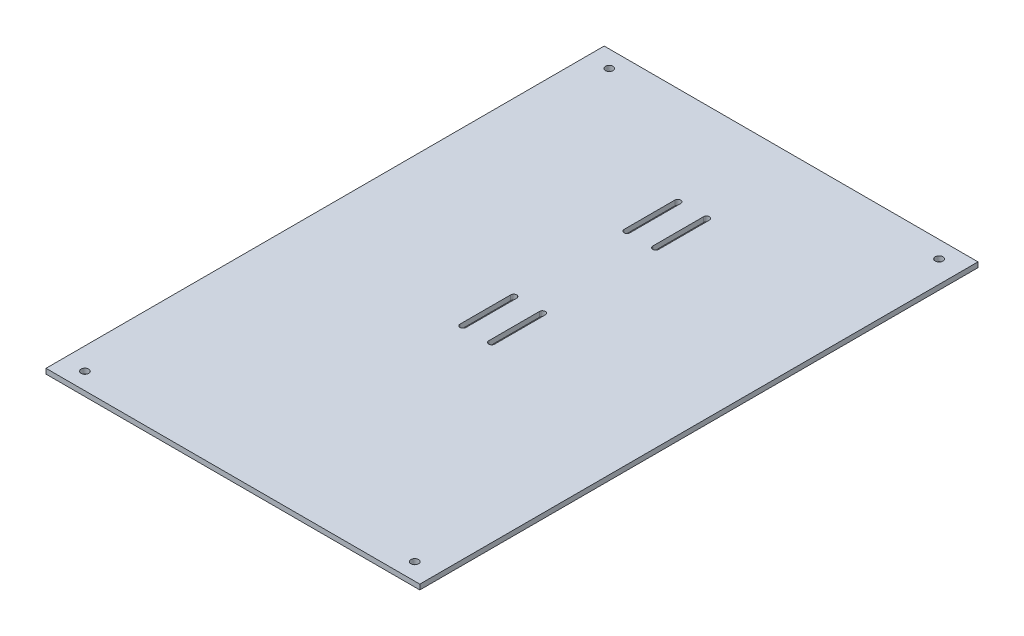
from build123d import *

# Parameters (mm, degrees)
SKETCH1_W                = 330
SKETCH1_H                = 3
EXTRUDE_THIN1_DEPTH      = 110.5
EXTRUDE_THIN1_DEPTH_BACK = 110.5
CUT_EXTRUDE1_REACH       = 5
SKETCH2_R                = 2.1
M4_CLEARANCE_HOLE1_D     = 4.5


with BuildPart() as part:
    # Sketch1 → Extrude-Thin1 (new body, two sides)
    with BuildSketch(Plane(origin=(0, 0, 0), x_dir=(0, 0, -1), z_dir=(1, 0, 0))) as extrude_thin1_sk:
        with Locations((-42.5, -11.5)):
            Rectangle(SKETCH1_W, SKETCH1_H)
    extrude(amount=EXTRUDE_THIN1_DEPTH)
    extrude(extrude_thin1_sk.sketch, amount=-EXTRUDE_THIN1_DEPTH_BACK)

    # Sketch2 → Cut-Extrude1 (cut, up to next)
    with BuildSketch(Plane.XZ.offset(13), mode=Mode.PRIVATE) as cut_extrude1_sk1:
        with Locations((97.5, -112.5)):
            Circle(SKETCH2_R)
    cut_extrude1_tool1 = extrude(cut_extrude1_sk1.sketch, amount=-CUT_EXTRUDE1_REACH, mode=Mode.PRIVATE) & part.part
    add(cut_extrude1_tool1.solids().sort_by_distance((97.5, -13, -112.5))[0], mode=Mode.SUBTRACT)
    # Sketch2 → Cut-Extrude1 (cut, up to next)
    with BuildSketch(Plane.XZ.offset(13), mode=Mode.PRIVATE) as cut_extrude1_sk2:
        with Locations((-97.5, -112.5)):
            Circle(SKETCH2_R)
    cut_extrude1_tool2 = extrude(cut_extrude1_sk2.sketch, amount=-CUT_EXTRUDE1_REACH, mode=Mode.PRIVATE) & part.part
    add(cut_extrude1_tool2.solids().sort_by_distance((-97.5, -13, -112.5))[0], mode=Mode.SUBTRACT)
    # Sketch2 → Cut-Extrude1 (cut, up to next)
    with BuildSketch(Plane.XZ.offset(13), mode=Mode.PRIVATE) as cut_extrude1_sk3:
        with Locations((97.5, 197.5)):
            Circle(SKETCH2_R)
    cut_extrude1_tool3 = extrude(cut_extrude1_sk3.sketch, amount=-CUT_EXTRUDE1_REACH, mode=Mode.PRIVATE) & part.part
    add(cut_extrude1_tool3.solids().sort_by_distance((97.5, -13, 197.5))[0], mode=Mode.SUBTRACT)
    # Sketch2 → Cut-Extrude1 (cut, up to next)
    with BuildSketch(Plane.XZ.offset(13), mode=Mode.PRIVATE) as cut_extrude1_sk4:
        with Locations((-97.5, 197.5)):
            Circle(SKETCH2_R)
    cut_extrude1_tool4 = extrude(cut_extrude1_sk4.sketch, amount=-CUT_EXTRUDE1_REACH, mode=Mode.PRIVATE) & part.part
    add(cut_extrude1_tool4.solids().sort_by_distance((-97.5, -13, 197.5))[0], mode=Mode.SUBTRACT)
    # Sketch2 → Cut-Extrude1 (cut, up to next)
    with BuildSketch(Plane.XZ.offset(13), mode=Mode.PRIVATE) as cut_extrude1_sk5:
        with BuildLine():
            Line((-7.243170513, -34.5), (-7.243170513, -64.5))
            ThreePointArc((-7.243170513, -64.5), (-8.993170513, -66.25), (-10.743170513, -64.5))
            Line((-10.743170513, -64.5), (-10.743170513, -34.5))
            ThreePointArc((-10.743170513, -34.5), (-8.993170513, -32.75), (-7.243170513, -34.5))
        make_face()
    cut_extrude1_tool5 = extrude(cut_extrude1_sk5.sketch, amount=-CUT_EXTRUDE1_REACH, mode=Mode.PRIVATE) & part.part
    add(cut_extrude1_tool5.solids().sort_by_distance((-8.993171, -13, -49.5))[0], mode=Mode.SUBTRACT)
    # Sketch2 → Cut-Extrude1 (cut, up to next)
    with BuildSketch(Plane.XZ.offset(13), mode=Mode.PRIVATE) as cut_extrude1_sk6:
        with BuildLine():
            Line((9.756829487, -34.5), (9.756829487, -64.5))
            ThreePointArc((9.756829487, -64.5), (8.006829487, -66.25), (6.256829487, -64.5))
            Line((6.256829487, -64.5), (6.256829487, -34.5))
            ThreePointArc((6.256829487, -34.5), (8.006829487, -32.75), (9.756829487, -34.5))
        make_face()
    cut_extrude1_tool6 = extrude(cut_extrude1_sk6.sketch, amount=-CUT_EXTRUDE1_REACH, mode=Mode.PRIVATE) & part.part
    add(cut_extrude1_tool6.solids().sort_by_distance((8.006829, -13, -49.5))[0], mode=Mode.SUBTRACT)
    # Sketch2 → Cut-Extrude1 (cut, up to next)
    with BuildSketch(Plane.XZ.offset(13), mode=Mode.PRIVATE) as cut_extrude1_sk7:
        with BuildLine():
            Line((9.756829487, 62.5), (9.756829487, 32.5))
            ThreePointArc((9.756829487, 32.5), (8.006829487, 30.75), (6.256829487, 32.5))
            Line((6.256829487, 32.5), (6.256829487, 62.5))
            ThreePointArc((6.256829487, 62.5), (8.006829487, 64.25), (9.756829487, 62.5))
        make_face()
    cut_extrude1_tool7 = extrude(cut_extrude1_sk7.sketch, amount=-CUT_EXTRUDE1_REACH, mode=Mode.PRIVATE) & part.part
    add(cut_extrude1_tool7.solids().sort_by_distance((8.006829, -13, 47.5))[0], mode=Mode.SUBTRACT)
    # Sketch2 → Cut-Extrude1 (cut, up to next)
    with BuildSketch(Plane.XZ.offset(13), mode=Mode.PRIVATE) as cut_extrude1_sk8:
        with BuildLine():
            Line((-7.243170513, 62.5), (-7.243170513, 32.5))
            ThreePointArc((-7.243170513, 32.5), (-8.993170513, 30.75), (-10.743170513, 32.5))
            Line((-10.743170513, 32.5), (-10.743170513, 62.5))
            ThreePointArc((-10.743170513, 62.5), (-8.993170513, 64.25), (-7.243170513, 62.5))
        make_face()
    cut_extrude1_tool8 = extrude(cut_extrude1_sk8.sketch, amount=-CUT_EXTRUDE1_REACH, mode=Mode.PRIVATE) & part.part
    add(cut_extrude1_tool8.solids().sort_by_distance((-8.993171, -13, 47.5))[0], mode=Mode.SUBTRACT)

    # M4 Clearance Hole1 (through all)
    with Locations(Plane.XZ.offset(13)):
        with Locations((-97.5, 197.5), (97.5, 197.5), (97.5, -112.5), (-97.5, -112.5)):
            Hole(M4_CLEARANCE_HOLE1_D / 2)


solid = part.part
